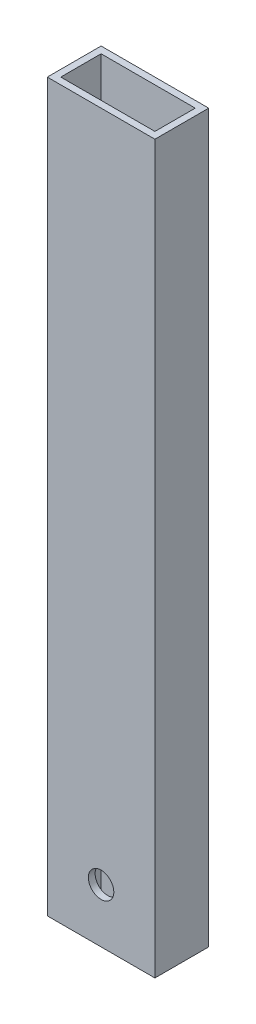
from build123d import *

# Parameters (mm, degrees)
SKETCH2_W            = 50.8
SKETCH2_H            = 25.4
SKETCH2_W_2          = 44.45
SKETCH2_H_2          = 19.05
EXTRUDE_THIN1_DEPTH  = 355.6
SKETCH25_W           = 50.8
SKETCH25_H           = 25.4
SKETCH25_W_2         = 44.45
SKETCH25_H_2         = 19.05
BOSS_EXTRUDE14_DEPTH = 25.4
CUT_EXTRUDE9_START   = -25.4
SKETCH28_R           = 6
CUT_EXTRUDE9_DEPTH   = 25.4
SKETCH30_W           = 50.8
SKETCH30_H           = 25.4
CUT_EXTRUDE11_DEPTH  = 38.1


with BuildPart() as part:
    # Sketch2 → Extrude-Thin1 (new body)
    with BuildSketch(Plane(origin=(0, 0, 0), x_dir=(1, 0, 0), z_dir=(0, 1, 0))):
        with Locations((10.213756614, 0.671957672)):
            Rectangle(SKETCH2_W, SKETCH2_H)
        with Locations((10.213756614, 0.671957672)):
            Rectangle(SKETCH2_W_2, SKETCH2_H_2, mode=Mode.SUBTRACT)
    extrude(amount=EXTRUDE_THIN1_DEPTH)

    # Sketch25 → Boss-Extrude14 (add)
    with BuildSketch(Plane.XZ):
        with Locations((10.213756614, -0.671957672)):
            Rectangle(SKETCH25_W, SKETCH25_H)
        with Locations((10.213756614, -0.671957672)):
            Rectangle(SKETCH25_W_2, SKETCH25_H_2, mode=Mode.SUBTRACT)
    extrude(amount=BOSS_EXTRUDE14_DEPTH)

    # Sketch28 → Cut-Extrude9 (cut)
    with BuildSketch(Plane(origin=(0, 0, -13.371957672), x_dir=(-1, 0, 0), z_dir=(0, 0, -1)).offset(CUT_EXTRUDE9_START)):
        with Locations((-10.213756614, 0)):
            Circle(SKETCH28_R)
    extrude(amount=CUT_EXTRUDE9_DEPTH, mode=Mode.SUBTRACT)

    # Sketch30 → Cut-Extrude11 (cut)
    with BuildSketch(Plane(origin=(0, 355.6, 0), x_dir=(1, 0, 0), z_dir=(0, 1, 0))):
        with Locations((10.213756614, 0.671957672)):
            Rectangle(SKETCH30_W, SKETCH30_H)
    extrude(amount=-CUT_EXTRUDE11_DEPTH, mode=Mode.SUBTRACT)


solid = part.part
